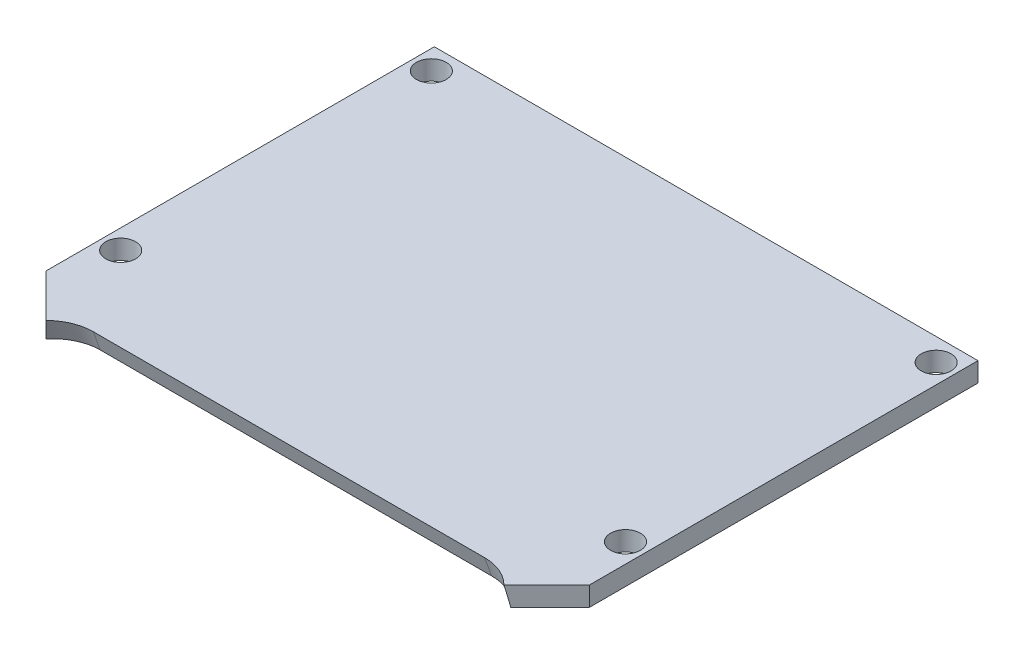
from build123d import *

# Parameters (mm, degrees)
BOSS_EXTRUDE1_DEPTH   = 1.5875
CUT_EXTRUDE3_DEPTH    = 18.601397685
F_2_CLEARANCE_HOLE1_D = 2.4384


with BuildPart() as part:
    # Sketch1 → Boss-Extrude1 (new body)
    with BuildSketch(Plane(origin=(0, 0, 0), x_dir=(1, 0, 0), z_dir=(0, 1, 0))):
        Polygon((-22.225, 0), (0, -22.225), (22.225, 0), (22.225, 31.75), (-22.225, 31.75), align=None)
    extrude(amount=BOSS_EXTRUDE1_DEPTH)

    # Sketch4 → Cut-Extrude3 (cut, through all)
    with BuildSketch(Plane(origin=(0, 17.622290844, -73.293269771), x_dir=(1, 0, 0), z_dir=(0, 0.939692621, 0.342020143))):
        with BuildLine():
            Line((0, -95.784991694), (18.997209487, -77.933454124))
            ThreePointArc((18.997209487, -77.933454124), (17.643829617, -76.935748034), (16, -76.58236622))
            Line((16, -76.58236622), (-16, -76.58236622))
            ThreePointArc((-16, -76.58236622), (-17.643829617, -76.935748034), (-18.997209487, -77.933454124))
            Line((-18.997209487, -77.933454124), (0, -95.784991694))
        make_face()
    extrude(amount=CUT_EXTRUDE3_DEPTH, mode=Mode.SUBTRACT)

    # #2 Clearance Hole1 (through all)
    with Locations(Plane(origin=(0, 1.5875, 5.174363579), x_dir=(0, 0, 1), z_dir=(0, 1, 0))):
        with Locations((-9.69048373, 20.6375), (-35.09048373, 20.6375), (-35.09048373, -20.6375), (-9.69048373, -20.6375)):
            Hole(F_2_CLEARANCE_HOLE1_D / 2)


solid = part.part
